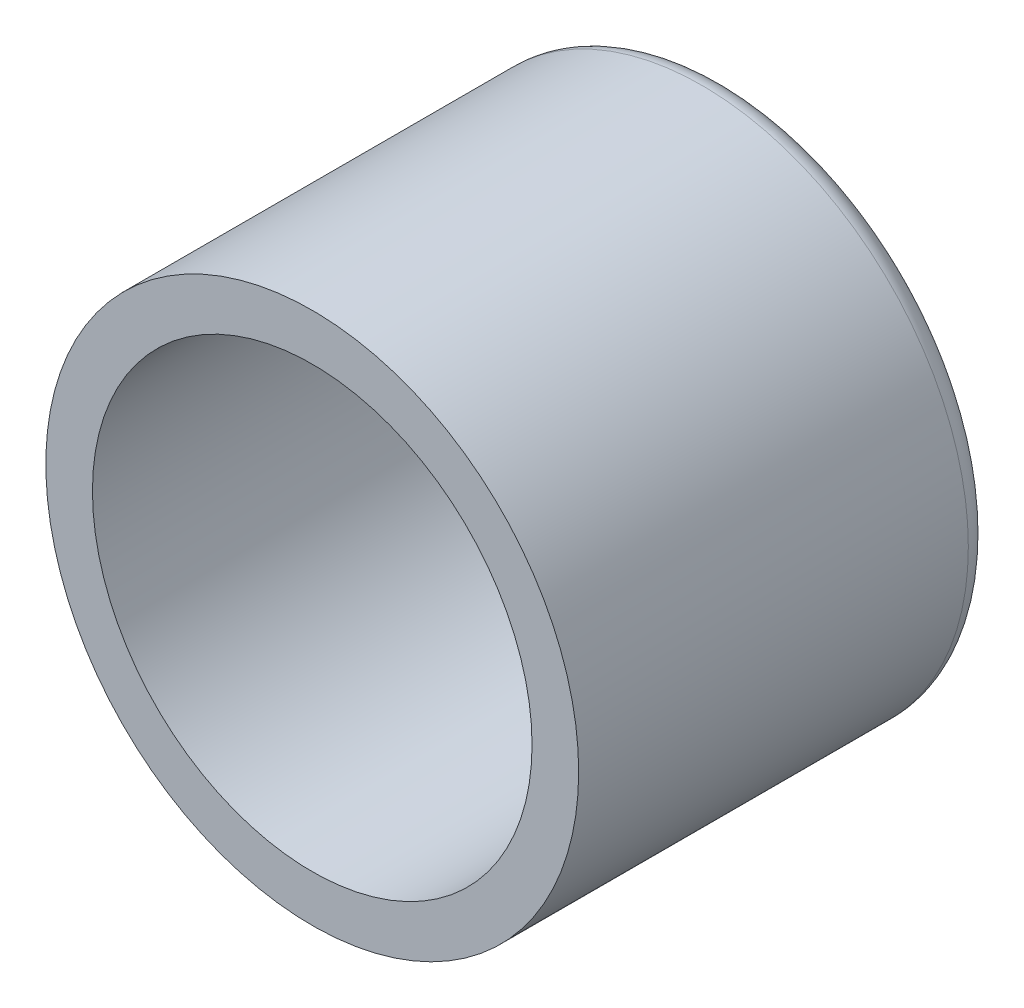
from build123d import *

# Parameters (mm, degrees)
CROQUIS1_R              = 8
CROQUIS1_R_2            = 6.6
SALIENTE_EXTRUIR1_DEPTH = 12.4
REDONDEO1_R             = 0.7


with BuildPart() as part:
    # Croquis1 → Saliente-Extruir1 (new body)
    with BuildSketch(Plane.XY):
        Circle(CROQUIS1_R)
        Circle(CROQUIS1_R_2, mode=Mode.SUBTRACT)
    extrude(amount=SALIENTE_EXTRUIR1_DEPTH)

    # Redondeo1
    redondeo1_edges = [part.edges().sort_by_distance(p)[0] for p in [
        (-8, 0, 0),
    ]]
    fillet(redondeo1_edges, radius=REDONDEO1_R)


solid = part.part
